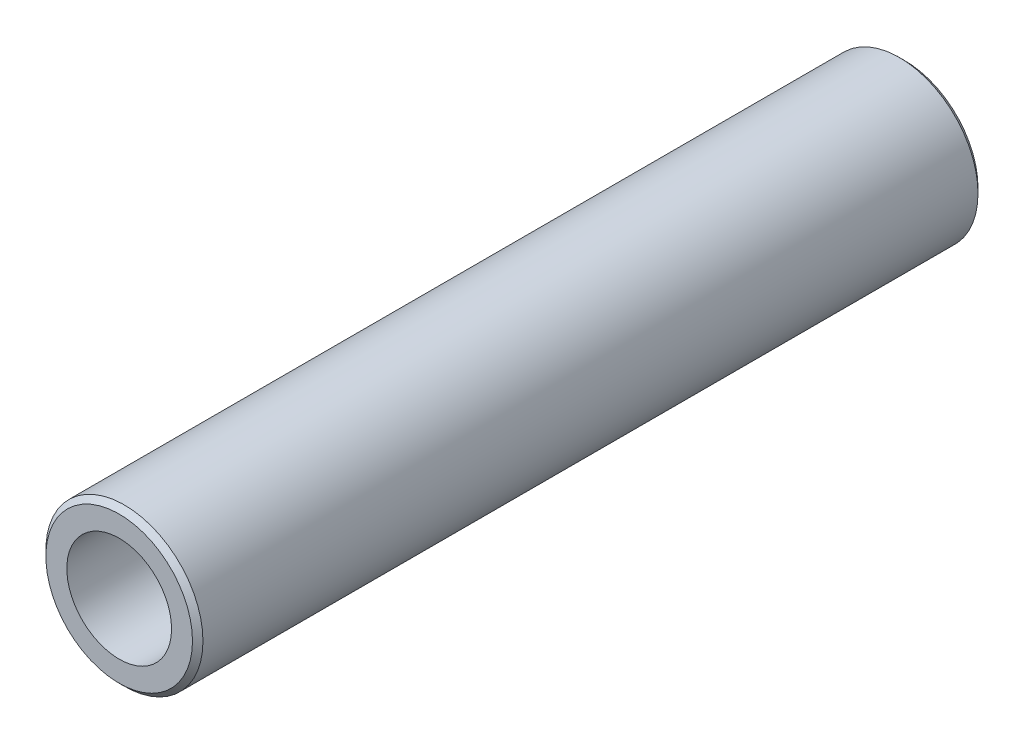
from build123d import *

# Parameters (mm, degrees)
SKETCH_1_R          = 3
EXTRUDE_1_DEPTH     = 30
SKETCH_2_R          = 1
CUT_EXTRUDE_1_DEPTH = 30
SKETCH_3_R          = 2
CUT_EXTRUDE_2_DEPTH = 20
CHAMFER_1_SIZE      = 1
CHAMFER_2_SIZE      = 0.2


with BuildPart() as part:
    # Эскиз1 → Бобышка-Вытянуть1 (new body)
    with BuildSketch(Plane.XY):
        Circle(SKETCH_1_R)
    extrude(amount=EXTRUDE_1_DEPTH)

    # Эскиз2 → Вырез-Вытянуть1 (cut)
    with BuildSketch(Plane.XY.offset(30)):
        Circle(SKETCH_2_R)
    extrude(amount=-CUT_EXTRUDE_1_DEPTH, mode=Mode.SUBTRACT)

    # Эскиз3 → Вырез-Вытянуть2 (cut)
    with BuildSketch(Plane.XY.offset(30)):
        Circle(SKETCH_3_R)
    extrude(amount=-CUT_EXTRUDE_2_DEPTH, mode=Mode.SUBTRACT)

    # Фаска1
    chamfer_1_edges = [part.edges().sort_by_distance(p)[0] for p in [
        (-1, 0, 0),
    ]]
    chamfer(chamfer_1_edges, length=CHAMFER_1_SIZE)

    # Фаска2
    chamfer_2_edges = [part.edges().sort_by_distance(p)[0] for p in [
        (-3, 0, 0),
        (-3, 0, 30),
    ]]
    chamfer(chamfer_2_edges, length=CHAMFER_2_SIZE)


solid = part.part
